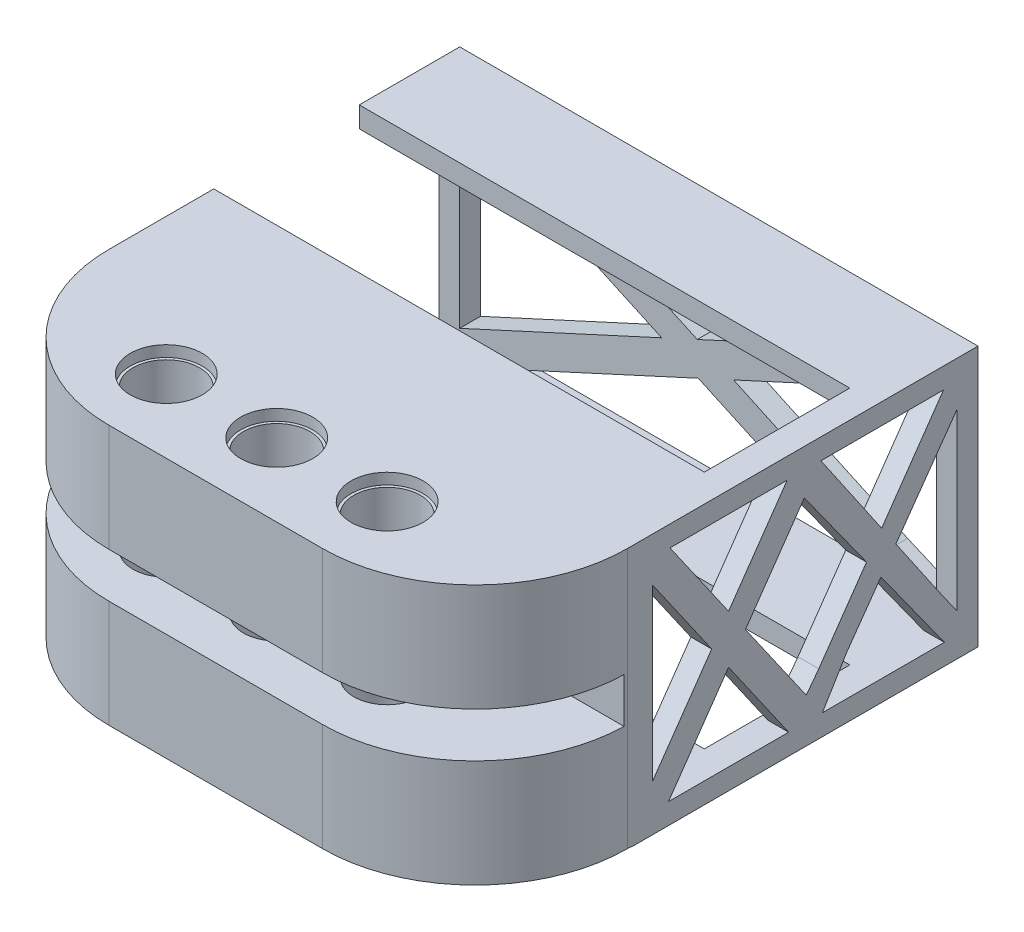
from build123d import *

# Parameters (mm, degrees)
SKETCH1_W            = 37.4
SKETCH1_H            = 18.8
BOSS_EXTRUDE1_DEPTH  = 2
SKETCH2_W            = 33.4
SKETCH2_H            = 15.8
BOSS_EXTRUDE2_DEPTH  = 23
SKETCH4_W            = 22
SKETCH4_H            = 15.8
CUT_EXTRUDE3_DEPTH   = 5550
SKETCH6_W            = 34.4
SKETCH6_H            = 15.8
CUT_EXTRUDE4_DEPTH   = 5550
CUT_EXTRUDE5_DEPTH   = 5550
BOSS_EXTRUDE3_DEPTH  = 1.5
BOSS_EXTRUDE4_DEPTH  = 1.5
BOSS_EXTRUDE5_DEPTH  = 1.5
SKETCH11_W           = 35.4
SKETCH11_H           = 5.25
BOSS_EXTRUDE6_DEPTH  = 1.5
SKETCH12_W           = 35.4
SKETCH12_H           = 7.25
BOSS_EXTRUDE7_DEPTH  = 1.5
SKETCH13_W           = 35.4
SKETCH13_H           = 5.25
BOSS_EXTRUDE8_DEPTH  = 1.5
SKETCH14_W           = 35.4
SKETCH14_H           = 5.25
BOSS_EXTRUDE9_DEPTH  = 1.5
SKETCH15_W           = 37.4
SKETCH15_H           = 2.35
BOSS_EXTRUDE10_DEPTH = 1.5
SKETCH16_W           = 37.4
SKETCH16_H           = 2.35
CUT_EXTRUDE6_DEPTH   = 10
SKETCH17_W           = 37.4
SKETCH17_H           = 11.3
SKETCH17_R           = 2.4
BOSS_EXTRUDE11_DEPTH = 18.76
FILLET2_R            = 11
FILLET3_R            = 11
SKETCH21_W           = 41.68561835
SKETCH21_H           = 3.24
CUT_EXTRUDE7_DEPTH   = 10.76
SKETCH22_R           = 2.6
CUT_EXTRUDE8_DEPTH   = 0.8
SKETCH23_R           = 2.6
CUT_EXTRUDE9_DEPTH   = 0.8


with BuildPart() as part:
    # Sketch1 → Boss-Extrude1 (new body)
    with BuildSketch(Plane.XY):
        with Locations((18.7, 9.4)):
            Rectangle(SKETCH1_W, SKETCH1_H)
    extrude(amount=BOSS_EXTRUDE1_DEPTH)

    # Sketch2 → Boss-Extrude2 (add)
    with BuildSketch(Plane.XY.offset(2)):
        Polygon((0, 18.8), (37.4, 18.8), (37.4, 17.3), (37.4, 0), (0, 0), (0, 16.8), align=None)
        with Locations((18.7, 9.4)):
            Rectangle(SKETCH2_W, SKETCH2_H, mode=Mode.SUBTRACT)
    extrude(amount=BOSS_EXTRUDE2_DEPTH)

    # Sketch4 → Cut-Extrude3 (cut)
    with BuildSketch(Plane.ZY):
        with Locations((12.5, 9.4)):
            Rectangle(SKETCH4_W, SKETCH4_H)
    extrude(amount=-CUT_EXTRUDE3_DEPTH, mode=Mode.SUBTRACT)

    # Sketch6 → Cut-Extrude4 (cut)
    with BuildSketch(Plane(origin=(0, 0, 0), x_dir=(-1, 0, 0), z_dir=(0, 0, -1))):
        with Locations((-18.7, 9.4)):
            Rectangle(SKETCH6_W, SKETCH6_H)
    extrude(amount=-CUT_EXTRUDE4_DEPTH, mode=Mode.SUBTRACT)

    # Sketch7 → Cut-Extrude5 (cut)
    with BuildSketch(Plane(origin=(0, 18.8, 0), x_dir=(1, 0, 0), z_dir=(0, 1, 0))):
        Polygon((1.635040334, -2), (35.4, -2), (35.4, -23), (1.635040334, -23), (0, -23), (0, -2), align=None)
    extrude(amount=-CUT_EXTRUDE5_DEPTH, mode=Mode.SUBTRACT)

    # Sketch8 → Boss-Extrude3 (add)
    with BuildSketch(Plane(origin=(0, 0, 0), x_dir=(-1, 0, 0), z_dir=(0, 0, -1))):
        Polygon((-35.9, 16.089041374), (-35.9, 17.3), (-33.263482485, 17.3), (-18.638089895, 10.582523171), (-4.136517515, 17.3), (-1.5, 17.3), (-1.5, 16.089041374), (-16.074159281, 9.404903878), (-5.039195107, 4.33651917), (-1.5, 2.710958626), (-1.5, 1.5), (-4.136517515, 1.5), (-5.957799758, 2.33651917), (-18.712609683, 8.194833031), (-31.486134971, 2.33651917), (-33.263482485, 1.5), (-35.9, 1.5), (-35.9, 2.710958626), (-32.318884833, 4.245250178), (-21.26339944, 9.366416698), align=None)
    extrude(amount=-BOSS_EXTRUDE3_DEPTH)

    # Sketch9 → Boss-Extrude4 (add)
    with BuildSketch(Plane.XY.offset(25)):
        Polygon((21.336517515, 9.4), (35.9, 16.089041374), (35.9, 17.3), (33.263482485, 17.3), (18.7, 10.610958626), (4.136517515, 17.3), (1.5, 17.3), (1.5, 16.089041374), (16.063482485, 9.4), (1.5, 2.710958626), (1.5, 1.5), (4.136517515, 1.5), (18.7, 8.189041374), (33.263482485, 1.5), (35.9, 1.5), (35.9, 2.710958626), align=None)
    extrude(amount=-BOSS_EXTRUDE4_DEPTH)

    # Sketch10 → Boss-Extrude5 (add)
    with BuildSketch(Plane(origin=(37.4, 0, 0), x_dir=(0, 0, -1), z_dir=(1, 0, 0))):
        Polygon((-23.5, 17.3), (-23.5, 15.627431355), (-19.218481828, 9.477614344), (-22.771372102, 4.374371951), (-23.5, 3.327797334), (-23.5, 1.5), (-22.335553475, 1.5), (-21.129985293, 3.231634299), (-18, 7.727431355), (-14.870014707, 3.231634299), (-13.664446525, 1.5), (-12.445964697, 1.5), (-11.227482869, 1.5), (-9.490525788, 4.374371951), (-7.004939959, 7.874823075), (-4.491504582, 4.374371951), (-2.427613988, 1.5), (-1.5, 1.5), (-1.5, 2.993507593), (-2.491504582, 4.374371951), (-5.926135142, 9.394104162), (-1.5, 15.627431355), (-1.5, 17.3), (-2.491504582, 17.3), (-6.951935611, 10.893317416), (-11.335553475, 17.3), (-13.772517131, 17.3), (-18, 11.227797334), (-22.227482869, 17.3), align=None)
        Polygon((-11.490525788, 4.374371951), (-12.395540567, 3.177755602), (-13.228627898, 4.374371951), (-16.781518172, 9.477614344), (-12.535227515, 15.576831834), (-8.044999313, 9.323309465), align=None, mode=Mode.SUBTRACT)
    extrude(amount=-BOSS_EXTRUDE5_DEPTH)

    # Sketch11 → Boss-Extrude6 (add)
    with BuildSketch(Plane(origin=(0, 18.8, 0), x_dir=(1, 0, 0), z_dir=(0, 1, 0))):
        with Locations((17.7, -4.625)):
            Rectangle(SKETCH11_W, SKETCH11_H)
    extrude(amount=-BOSS_EXTRUDE6_DEPTH)

    # Sketch12 → Boss-Extrude7 (add)
    with BuildSketch(Plane(origin=(0, 18.8, 0), x_dir=(1, 0, 0), z_dir=(0, 1, 0))):
        with Locations((17.7, -21.375)):
            Rectangle(SKETCH12_W, SKETCH12_H)
    extrude(amount=-BOSS_EXTRUDE7_DEPTH)

    # Sketch13 → Boss-Extrude8 (add)
    with BuildSketch(Plane.XZ):
        with Locations((17.7, 20.375)):
            Rectangle(SKETCH13_W, SKETCH13_H)
    extrude(amount=-BOSS_EXTRUDE8_DEPTH)

    # Sketch14 → Boss-Extrude9 (add)
    with BuildSketch(Plane.XZ):
        with Locations((17.7, 4.625)):
            Rectangle(SKETCH14_W, SKETCH14_H)
    extrude(amount=-BOSS_EXTRUDE9_DEPTH)

    # Sketch15 → Boss-Extrude10 (add)
    with BuildSketch(Plane(origin=(0, 18.8, 0), x_dir=(1, 0, 0), z_dir=(0, 1, 0))):
        with Locations((18.7, 1.175)):
            Rectangle(SKETCH15_W, SKETCH15_H)
    extrude(amount=-BOSS_EXTRUDE10_DEPTH)

    # Sketch16 → Cut-Extrude6 (cut)
    with BuildSketch(Plane(origin=(0, 18.8, 0), x_dir=(1, 0, 0), z_dir=(0, 1, 0))):
        with Locations((18.7, 1.175)):
            Rectangle(SKETCH16_W, SKETCH16_H)
    extrude(amount=-CUT_EXTRUDE6_DEPTH, mode=Mode.SUBTRACT)

    # Sketch17 → Boss-Extrude11 (add)
    with BuildSketch(Plane(origin=(0, 18.8, 0), x_dir=(1, 0, 0), z_dir=(0, 1, 0))):
        with Locations((18.7, -30.65)):
            Rectangle(SKETCH17_W, SKETCH17_H)
        with Locations((25.8, -31.04)):
            Circle(SKETCH17_R, mode=Mode.SUBTRACT)
        with Locations((17.83, -31.04)):
            Circle(SKETCH17_R, mode=Mode.SUBTRACT)
        with Locations((9.86, -31.04)):
            Circle(SKETCH17_R, mode=Mode.SUBTRACT)
    extrude(amount=-BOSS_EXTRUDE11_DEPTH)

    # Fillet2
    fillet2_edges = [part.edges().sort_by_distance(p)[0] for p in [
        (0, 9.42, 36.3),
    ]]
    fillet(fillet2_edges, radius=FILLET2_R)

    # Fillet3
    fillet3_edges = [part.edges().sort_by_distance(p)[0] for p in [
        (37.4, 9.42, 36.3),
    ]]
    fillet(fillet3_edges, radius=FILLET3_R)

    # Sketch21 → Cut-Extrude7 (cut)
    with BuildSketch(Plane.XY.offset(36.3)):
        with Locations((18.29957708, 9.42)):
            Rectangle(SKETCH21_W, SKETCH21_H)
    extrude(amount=-CUT_EXTRUDE7_DEPTH, mode=Mode.SUBTRACT)

    # Sketch22 → Cut-Extrude8 (cut)
    with BuildSketch(Plane.XZ.offset(-0.04)):
        with Locations((9.86, 31.04)):
            Circle(SKETCH22_R)
        with Locations((17.83, 31.04)):
            Circle(SKETCH22_R)
        with Locations((25.8, 31.04)):
            Circle(SKETCH22_R)
    extrude(amount=-CUT_EXTRUDE8_DEPTH, mode=Mode.SUBTRACT)

    # Sketch23 → Cut-Extrude9 (cut)
    with BuildSketch(Plane(origin=(0, 18.8, 0), x_dir=(1, 0, 0), z_dir=(0, 1, 0))):
        with Locations((9.86, -31.04)):
            Circle(SKETCH23_R)
        with Locations((17.83, -31.04)):
            Circle(SKETCH23_R)
        with Locations((25.8, -31.04)):
            Circle(SKETCH23_R)
    extrude(amount=-CUT_EXTRUDE9_DEPTH, mode=Mode.SUBTRACT)


solid = part.part
